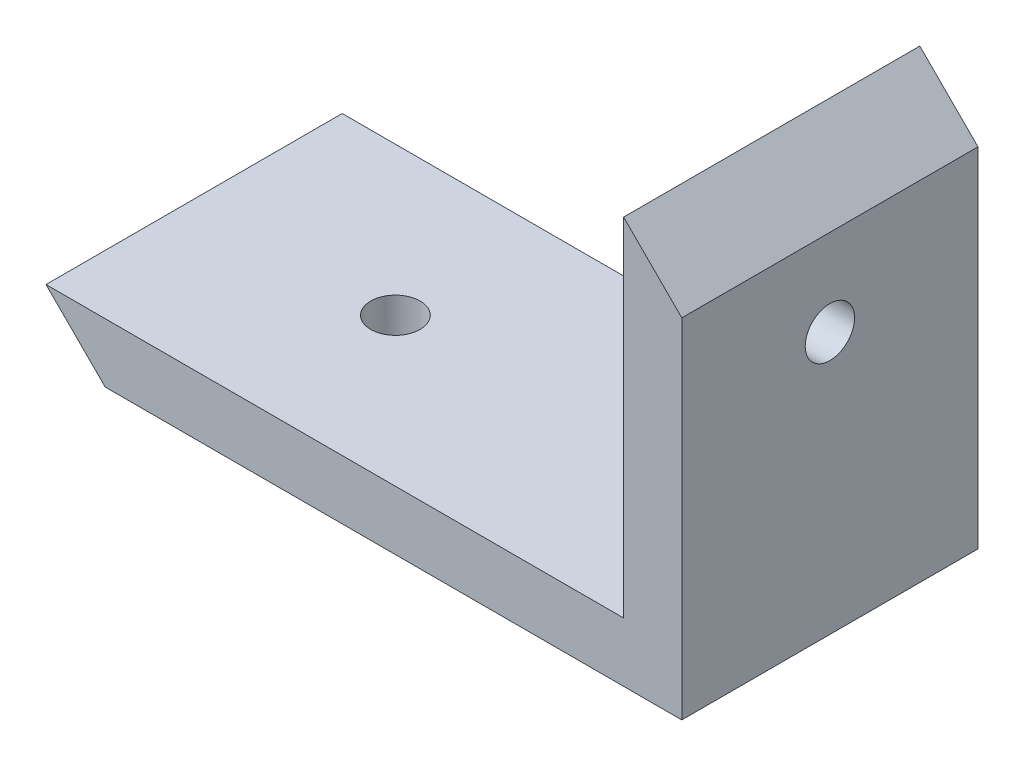
from build123d import *

# Parameters (mm, degrees)
IZIM1_W                     = 60
IZIM1_H                     = 30
Y_KSEKLIK_EKSTR_ZYON1_DEPTH = 30
KES_EKSTR_ZYON1_DEPTH       = 30
IZIM3_W                     = 60.882003546
IZIM3_H                     = 31.045979635
KES_EKSTR_ZYON2_DEPTH       = 68
IZIM5_R                     = 1.5
KES_EKSTR_ZYON3_DEPTH       = 68
KES_EKSTR_ZYON6_DEPTH       = 68
KES_EKSTR_ZYON6_DEPTH_BACK  = 68
IZIM6_W                     = 6
IZIM6_H                     = 30
IZIM7_R                     = 1.5
KES_EKSTR_ZYON7_DEPTH       = 68
IZIM8_W                     = 21.364552878
IZIM8_H                     = 18
KES_EKSTR_ZYON8_DEPTH       = 68
KES_EKSTR_ZYON9_DEPTH       = 68
KES_EKSTR_ZYON10_DEPTH      = 68
KES_EKSTR_ZYON11_DEPTH      = 68
KES_EKSTR_ZYON12_DEPTH      = 68


with BuildPart() as part:
    # Çizim1 → Yükseklik-Ekstrüzyon1 (new body)
    with BuildSketch(Plane(origin=(0, 0, 0), x_dir=(1, 0, 0), z_dir=(0, 1, 0))):
        with Locations((2.921722845, -2.96539542)):
            Rectangle(IZIM1_W, IZIM1_H)
    extrude(amount=Y_KSEKLIK_EKSTR_ZYON1_DEPTH)

    # Çizim2 → Kes-Ekstrüzyon1 (cut)
    with BuildSketch(Plane.XY.offset(17.96539542)):
        Polygon((-27.078277155, 0), (32.921722845, 30), (-27.078277155, 30), align=None)
    extrude(amount=-KES_EKSTR_ZYON1_DEPTH, mode=Mode.SUBTRACT)

    # Çizim3 → Kes-Ekstrüzyon2 (cut)
    with BuildSketch(Plane.XY.offset(17.96539542)):
        with Locations((-1.054812834, 19.120649243)):
            Rectangle(IZIM3_W, IZIM3_H)
    extrude(amount=-KES_EKSTR_ZYON2_DEPTH, mode=Mode.SUBTRACT)

    # Çizim5 → Kes-Ekstrüzyon3 (cut)
    with BuildSketch(Plane.ZY.offset(-29.386188939)):
        with Locations((2.96539542, 15.914946236)):
            Circle(IZIM5_R)
    extrude(amount=-KES_EKSTR_ZYON3_DEPTH, mode=Mode.SUBTRACT)

    # Çizim6 → Kes-Ekstrüzyon6 (cut, two sides: drawn at the far end of the back side and taken through both)
    with BuildSketch(Plane.ZY.offset(-29.386188939).offset(-KES_EKSTR_ZYON6_DEPTH_BACK)):
        with Locations((-9.03460458, 15)):
            Rectangle(IZIM6_W, IZIM6_H)
        with Locations((14.96539542, 15)):
            Rectangle(IZIM6_W, IZIM6_H)
    extrude(amount=KES_EKSTR_ZYON6_DEPTH + KES_EKSTR_ZYON6_DEPTH_BACK, mode=Mode.SUBTRACT)

    # Çizim7 → Kes-Ekstrüzyon7 (cut)
    with BuildSketch(Plane(origin=(0, 3.597659425, 0), x_dir=(1, 0, 0), z_dir=(0, 1, 0))):
        with Locations((6.51938227, -2.96539542)):
            Circle(IZIM7_R)
    extrude(amount=-KES_EKSTR_ZYON7_DEPTH, mode=Mode.SUBTRACT)

    # Çizim8 → Kes-Ekstrüzyon8 (cut)
    with BuildSketch(Plane(origin=(0, 3.597659425, 0), x_dir=(1, 0, 0), z_dir=(0, 1, 0))):
        with Locations((-16.396000716, -2.96539542)):
            Rectangle(IZIM8_W, IZIM8_H)
    extrude(amount=-KES_EKSTR_ZYON8_DEPTH, mode=Mode.SUBTRACT)

    # Çizim9 → Kes-Ekstrüzyon9 (cut)
    with BuildSketch(Plane.XY.offset(11.96539542)):
        Polygon((-5.713724277, 3.597659425), (-2.116064853, 0), (-5.713724277, 0), align=None)
    extrude(amount=-KES_EKSTR_ZYON9_DEPTH, mode=Mode.SUBTRACT)

    # Çizim10 → Kes-Ekstrüzyon10 (cut)
    with BuildSketch(Plane.XY.offset(11.96539542)):
        Polygon((29.386188939, 28.232233047), (32.921722845, 24.696699141), (29.386188939, 24.696699141), align=None)
    extrude(amount=-KES_EKSTR_ZYON10_DEPTH, mode=Mode.SUBTRACT)


with BuildPart() as kes_ekstr_zyon10_piece_1:
    # of the separate pieces the step leaves, piece 1, a body of its own (kes_ekstr_zyon10_pieces)
    add(part.part.solids().sort_by_distance((32.921722845, 0, -6.03460458))[0])

    # Çizim12 → Kes-Ekstrüzyon12 (cut)
    with BuildSketch(Plane.XY.offset(11.96539542)):
        Polygon((29.386188939, 24.696699141), (32.921722845, 21.161165235), (32.921722845, 24.696699141), align=None)
    extrude(amount=-KES_EKSTR_ZYON12_DEPTH, mode=Mode.SUBTRACT)


with BuildPart() as kes_ekstr_zyon10_piece_2:
    # of the separate pieces the step leaves, piece 2, a body of its own (kes_ekstr_zyon10_pieces)
    add(part.part.solids().sort_by_distance((32.921722845, 30, 11.96539542))[0])

    # Çizim11 → Kes-Ekstrüzyon11 (cut)
    with BuildSketch(Plane.XY.offset(11.96539542)):
        Polygon((29.386188939, 28.232233047), (32.921722845, 30), (32.921722845, 24.696699141), align=None)
    extrude(amount=-KES_EKSTR_ZYON11_DEPTH, mode=Mode.SUBTRACT)


solid = kes_ekstr_zyon10_piece_1.part
